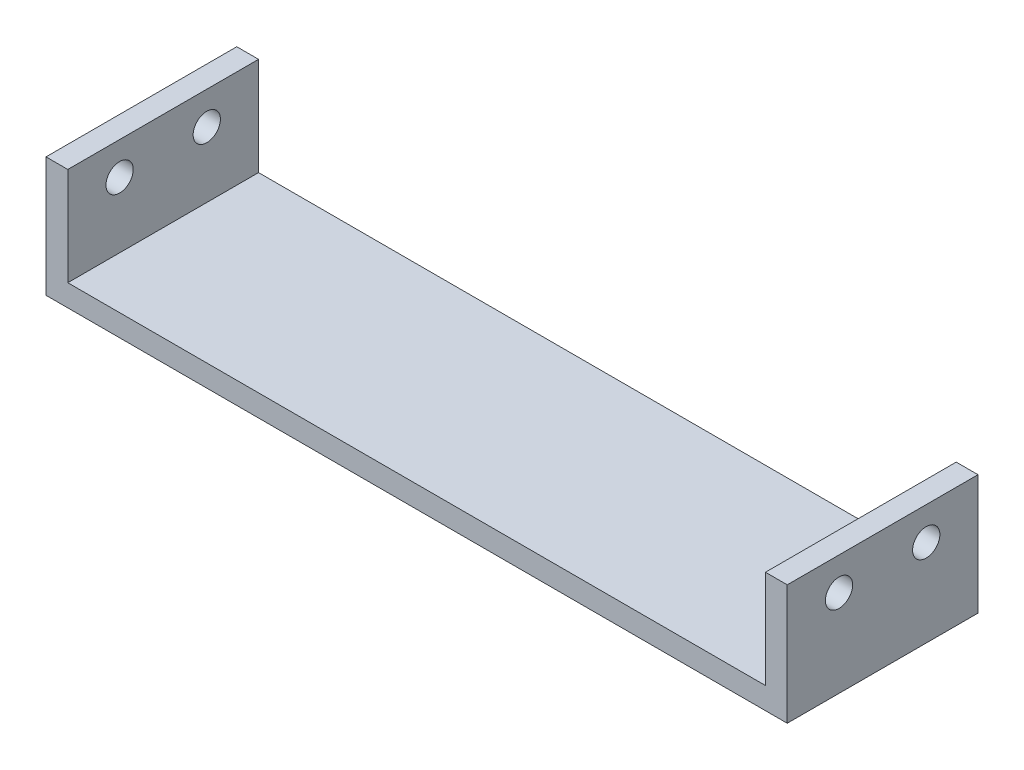
from build123d import *

# Parameters (mm, degrees)
SKETCH1_W           = 17.5
SKETCH1_H           = 11
BOSS_EXTRUDE1_DEPTH = 2
SKETCH2_W           = 17.5
SKETCH2_H           = 2
BOSS_EXTRUDE2_DEPTH = 64
SKETCH3_W           = 17.5
SKETCH3_H           = 11
BOSS_EXTRUDE3_DEPTH = 2
SKETCH4_R           = 1.25
CUT_EXTRUDE1_DEPTH  = 68


with BuildPart() as part:
    # Sketch1 → Boss-Extrude1 (new body)
    with BuildSketch(Plane(origin=(0, 0, 0), x_dir=(0, 0, -1), z_dir=(1, 0, 0))):
        with Locations((-48.014351082, 3.54)):
            Rectangle(SKETCH1_W, SKETCH1_H)
    extrude(amount=BOSS_EXTRUDE1_DEPTH)

    # Sketch2 → Boss-Extrude2 (add)
    with BuildSketch(Plane(origin=(2, 0, 0), x_dir=(0, 0, -1), z_dir=(1, 0, 0))):
        with Locations((-48.014351082, -0.96)):
            Rectangle(SKETCH2_W, SKETCH2_H)
    extrude(amount=BOSS_EXTRUDE2_DEPTH)

    # Sketch3 → Boss-Extrude3 (add)
    with BuildSketch(Plane(origin=(66, 0, 0), x_dir=(0, 0, -1), z_dir=(1, 0, 0))):
        with Locations((-48.014351082, 3.54)):
            Rectangle(SKETCH3_W, SKETCH3_H)
    extrude(amount=BOSS_EXTRUDE3_DEPTH)

    # Sketch4 → Cut-Extrude1 (cut)
    with BuildSketch(Plane(origin=(68, 0, 0), x_dir=(0, 0, -1), z_dir=(1, 0, 0))):
        with Locations((-52.014351082, 6.04)):
            Circle(SKETCH4_R)
        with Locations((-44.014351082, 6.04)):
            Circle(SKETCH4_R)
    extrude(amount=-CUT_EXTRUDE1_DEPTH, mode=Mode.SUBTRACT)


solid = part.part
